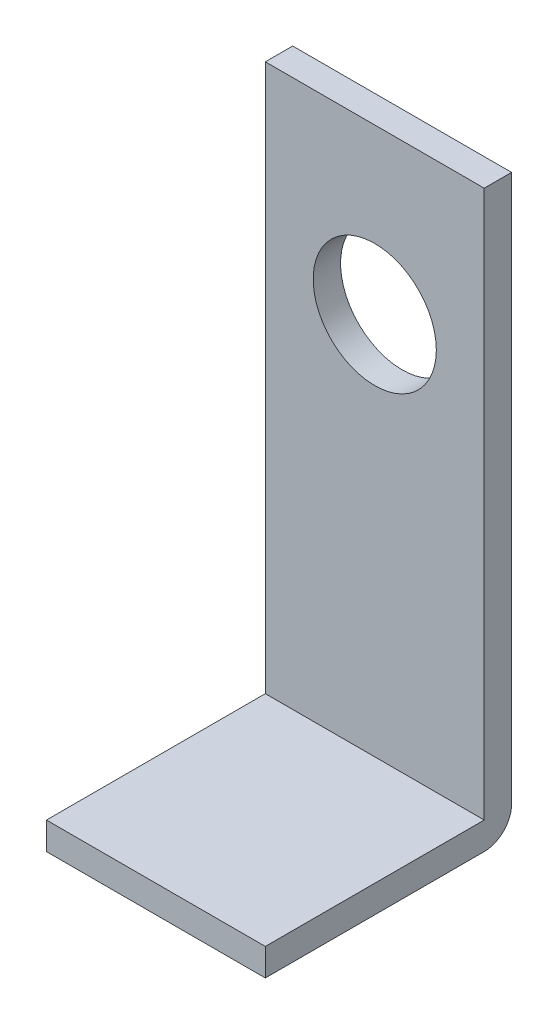
from build123d import *

# Parameters (mm, degrees)
SKETCH1_W           = 25.4
SKETCH1_H           = 63.5
BOSS_EXTRUDE1_DEPTH = 3.175
SKETCH2_W           = 25.4
SKETCH2_H           = 3.175
BOSS_EXTRUDE2_DEPTH = 25.4
BOSS_EXTRUDE3_DEPTH = 25.4
SKETCH4_R           = 7.14375
CUT_EXTRUDE1_DEPTH  = 4.175


with BuildPart() as part:
    # Sketch1 → Boss-Extrude1 (new body)
    with BuildSketch(Plane.XY):
        Rectangle(SKETCH1_W, SKETCH1_H)
    extrude(amount=BOSS_EXTRUDE1_DEPTH)



with BuildPart() as body_2:
    # Sketch2 → Boss-Extrude2 (new body)
    with BuildSketch(Plane(origin=(12.7, 0, 0), x_dir=(0, 0, -1), z_dir=(1, 0, 0))):
        with Locations((-15.875, -33.3375)):
            Rectangle(SKETCH2_W, SKETCH2_H)
    extrude(amount=-BOSS_EXTRUDE2_DEPTH)


with BuildPart() as part_1:
    add(part.part)

    add(body_2.part)  # Boss-Extrude3 merges body 2
    # Sketch3 → Boss-Extrude3 (add)
    with BuildSketch(Plane(origin=(12.7, 0, 0), x_dir=(0, 0, -1), z_dir=(1, 0, 0))):
        with BuildLine():
            Line((0, -31.75), (-3.175, -31.75))
            Line((-3.175, -31.75), (-3.175, -34.925))
            ThreePointArc((-3.175, -34.925), (-0.92993597, -33.99506403), (0, -31.75))
        make_face()
    extrude(amount=-BOSS_EXTRUDE3_DEPTH)

    # Sketch4 → Cut-Extrude1 (cut, through all)
    with BuildSketch(Plane.XY.offset(3.175)):
        with Locations((0, 12.7)):
            Circle(SKETCH4_R)
    extrude(amount=-CUT_EXTRUDE1_DEPTH, mode=Mode.SUBTRACT)


solid = part_1.part
